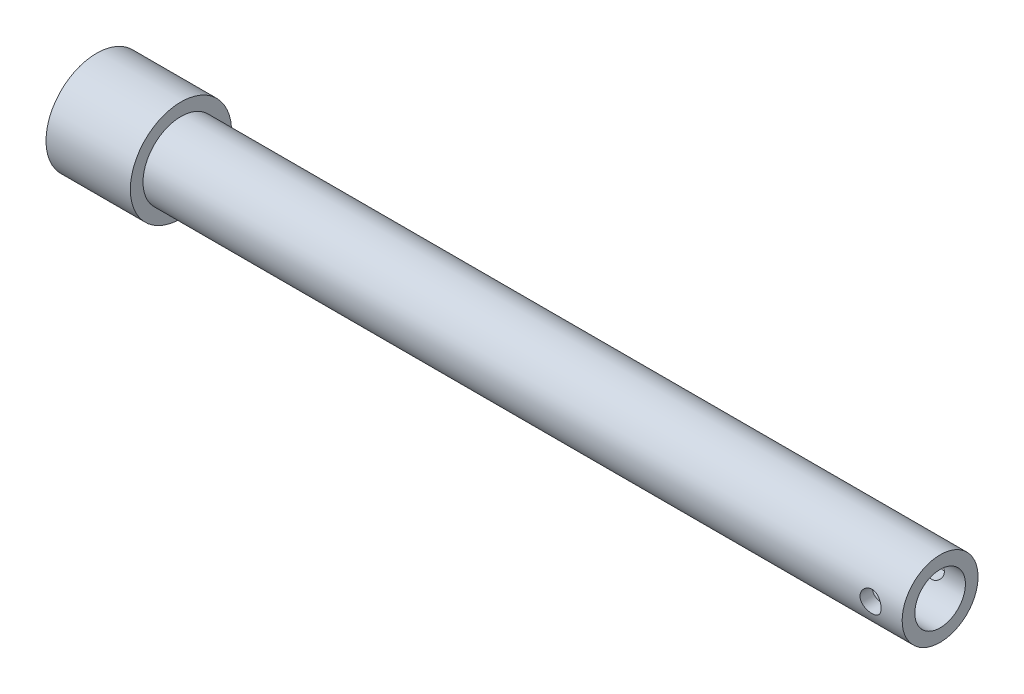
from build123d import *

# Parameters (mm, degrees)
SKETCH2_R               = 2.5
CUT_EXTRUDE1_DEPTH      = 13
CUT_EXTRUDE1_DEPTH_BACK = 13


with BuildPart() as part:
    # Sketch1 → Revolve1 (revolve)
    with BuildSketch(Plane.XY):
        Polygon((0, 0), (20, 0), (20, -6), (200, -6), (200, -9), (20, -9), (20, -12), (0, -12), align=None)
    revolve(axis=Axis((0, 0, 0), (1, 0, 0)))

    # Sketch2 → Cut-Extrude1 (cut, two sides)
    with BuildSketch(Plane.XY) as cut_extrude1_sk:
        with Locations((192.5, 0)):
            Circle(SKETCH2_R)
    extrude(amount=CUT_EXTRUDE1_DEPTH, mode=Mode.SUBTRACT)
    extrude(cut_extrude1_sk.sketch, amount=-CUT_EXTRUDE1_DEPTH_BACK, mode=Mode.SUBTRACT)


solid = part.part
